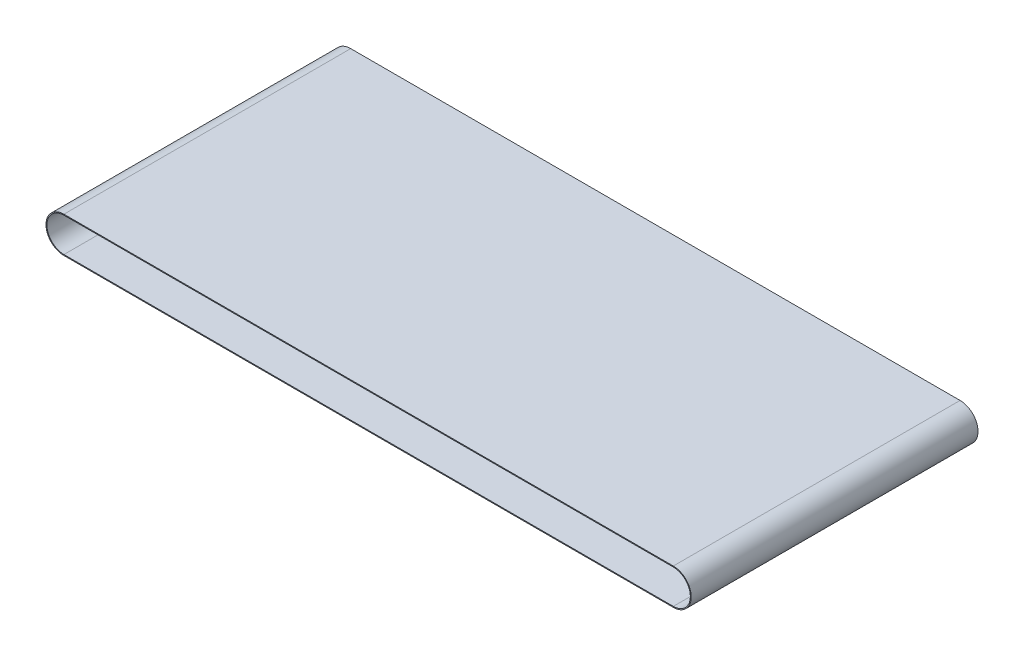
from build123d import *

# Parameters (mm, degrees)
SALIENTE_EXTRUIR1_DEPTH = 400


with BuildPart() as part:
    # Croquis1 → Saliente-Extruir1 (new body)
    with BuildSketch(Plane.XY):
        with BuildLine():
            Line((-425, 25), (425, 25))
            ThreePointArc((425, 25), (450, 0), (425, -25))
            Line((425, -25), (-425, -25))
            ThreePointArc((-425, -25), (-450, 0), (-425, 25))
        make_face()
        with BuildLine():
            Line((-425, 23.75), (425, 23.75))
            ThreePointArc((425, 23.75), (448.75, 0), (425, -23.75))
            Line((425, -23.75), (-425, -23.75))
            ThreePointArc((-425, -23.75), (-448.75, 0), (-425, 23.75))
        make_face(mode=Mode.SUBTRACT)
    extrude(amount=SALIENTE_EXTRUIR1_DEPTH)


solid = part.part
